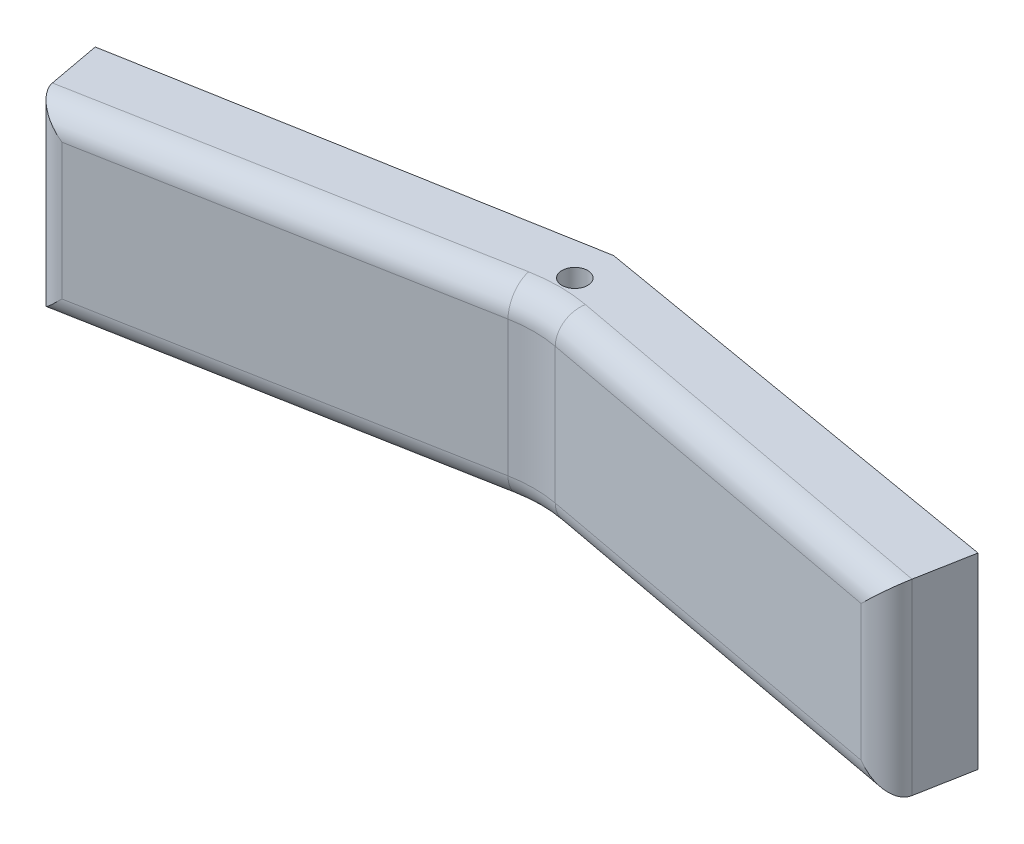
from build123d import *

# Parameters (mm, degrees)
ESQUISSE1_W              = 140
ESQUISSE1_H              = 30
BOSS_EXTRU_1_DEPTH       = 20
ESQUISSE3_W              = 140
ESQUISSE3_H              = 30
BOSS_EXTRU_2_DEPTH       = 20
BOSS_EXTRU_3_DEPTH       = 30
BOSS_EXTRU_4_DEPTH       = 30
ESQUISSE12_W             = 140
ESQUISSE12_H             = 30
ENL_V_MAT_EXTRU_1_DEPTH  = 41
ESQUISSE13_R             = 2
ENL_V_MAT_EXTRU_2_DEPTH  = 31
ESQUISSE25_R             = 2.5
ENL_V_MAT_EXTRU_11_DEPTH = 3
ENL_V_MAT_EXTRU_5_DEPTH  = 31
ENL_V_MAT_EXTRU_6_DEPTH  = 31
ESQUISSE19_W             = 12.781453569
ESQUISSE19_H             = 30
ENL_V_MAT_EXTRU_7_DEPTH  = 2
ESQUISSE20_W             = 12.289859201
ESQUISSE20_H             = 30
ENL_V_MAT_EXTRU_8_DEPTH  = 2
ENL_V_MAT_EXTRU_9_DEPTH  = 0.5
ENL_V_MAT_EXTRU_10_DEPTH = 0.5
ESQUISSE15_R             = 2.5
ENL_V_MAT_EXTRU_15_DEPTH = 3
CONG_1_R                 = 20
CONG_3_R                 = 4


with BuildPart() as part:
    # Esquisse1 → Boss.-Extru.1 (new body)
    with BuildSketch(Plane.XY):
        with Locations((70, 15)):
            Rectangle(ESQUISSE1_W, ESQUISSE1_H)
    extrude(amount=BOSS_EXTRU_1_DEPTH)

    # Esquisse3 → Boss.-Extru.2 (add)
    with BuildSketch(Plane.XY.offset(20)):
        with Locations((70, 15)):
            Rectangle(ESQUISSE3_W, ESQUISSE3_H)
    extrude(amount=BOSS_EXTRU_2_DEPTH)

    # Esquisse5 → Boss.-Extru.3 (add)
    with BuildSketch(Plane.XZ):
        Polygon((70, 12), (140, 25), (140, 12), (70, 0), align=None)
    extrude(amount=BOSS_EXTRU_3_DEPTH)

    # Esquisse6 → Boss.-Extru.4 (add)
    with BuildSketch(Plane.XZ):
        Polygon((0, 25), (0, 12.5), (70, 0), (70, 12), align=None)
    extrude(amount=BOSS_EXTRU_4_DEPTH)

    # Esquisse12 → Enlèv. mat.-Extru.1 (cut, through all)
    with BuildSketch(Plane.XY.offset(40)):
        with Locations((70, 15)):
            Rectangle(ESQUISSE12_W, ESQUISSE12_H)
    extrude(amount=-ENL_V_MAT_EXTRU_1_DEPTH, mode=Mode.SUBTRACT)

    # Esquisse13 → Enlèv. mat.-Extru.2 (cut, through all)
    with BuildSketch(Plane.XZ.offset(30)):
        with Locations((70, 6)):
            Circle(ESQUISSE13_R)
    extrude(amount=-ENL_V_MAT_EXTRU_2_DEPTH, mode=Mode.SUBTRACT)

    # Esquisse25 → Enlèv. mat.-Extru.11 (cut)
    with BuildSketch(Plane(origin=(2.1631644, 0, 12.113720643), x_dir=(-0.984427576, 0, 0.175790638), z_dir=(-0.175790638, 0, -0.984427576))):
        with Locations((-12.309930286, -15)):
            Circle(ESQUISSE25_R)
    extrude(amount=-ENL_V_MAT_EXTRU_11_DEPTH, mode=Mode.SUBTRACT)

    # Esquisse16 → Enlèv. mat.-Extru.5 (cut, through all)
    with BuildSketch(Plane(origin=(0, 0, 0), x_dir=(1, 0, 0), z_dir=(0, 1, 0))):
        Polygon((0, -12.5), (2.244032354, -24.583251134), (0, -25), align=None)
    extrude(amount=-ENL_V_MAT_EXTRU_5_DEPTH, mode=Mode.SUBTRACT)

    # Esquisse17 → Enlèv. mat.-Extru.6 (cut, through all)
    with BuildSketch(Plane(origin=(0, 0, 0), x_dir=(1, 0, 0), z_dir=(0, 1, 0))):
        Polygon((140, -12), (137.666206352, -24.56658118), (140, -25), align=None)
    extrude(amount=-ENL_V_MAT_EXTRU_6_DEPTH, mode=Mode.SUBTRACT)

    # Esquisse19 → Enlèv. mat.-Extru.7 (cut)
    with BuildSketch(Plane(origin=(137.486683764, 0, 25.53324127), x_dir=(0.182592194, 0, -0.983188736), z_dir=(0.983188736, 0, 0.182592194))):
        with Locations((7.373915521, -15)):
            Rectangle(ESQUISSE19_W, ESQUISSE19_H)
    extrude(amount=-ENL_V_MAT_EXTRU_7_DEPTH, mode=Mode.SUBTRACT)

    # Esquisse20 → Enlèv. mat.-Extru.8 (cut)
    with BuildSketch(Plane(origin=(-2.244032354, 0, 0.416748866), x_dir=(0.182592194, 0, 0.983188736), z_dir=(-0.983188736, 0, 0.182592194))):
        with Locations((18.434788802, -15)):
            Rectangle(ESQUISSE20_W, ESQUISSE20_H)
    extrude(amount=-ENL_V_MAT_EXTRU_8_DEPTH, mode=Mode.SUBTRACT)

    # Esquisse22 → Enlèv. mat.-Extru.9 (cut)
    with BuildSketch(Plane.XZ.offset(30)):
        Polygon((4.210409826, 24.218066747), (1.968902204, 12.148410321), (70, 0), (138.028566573, 11.662039984), (135.69982888, 24.201396792), (70, 12), align=None)
    extrude(amount=-ENL_V_MAT_EXTRU_9_DEPTH, mode=Mode.SUBTRACT)

    # Esquisse23 → Enlèv. mat.-Extru.10 (cut)
    with BuildSketch(Plane(origin=(0, 0, 0), x_dir=(1, 0, 0), z_dir=(0, 1, 0))):
        Polygon((1.968902204, -12.148410321), (4.210409826, -24.218066747), (70, -12), (135.69982888, -24.201396792), (138.028566573, -11.662039984), (70, 0), align=None)
    extrude(amount=-ENL_V_MAT_EXTRU_10_DEPTH, mode=Mode.SUBTRACT)

    # Esquisse15 → Enlèv. mat.-Extru.15 (cut)
    with BuildSketch(Plane(origin=(1.998413957, 0, -11.65741475), x_dir=(-0.985622255, 0, -0.168963815), z_dir=(0.168963815, 0, -0.985622255))):
        with Locations((-125.593557837, -15)):
            Circle(ESQUISSE15_R)
    extrude(amount=-ENL_V_MAT_EXTRU_15_DEPTH, mode=Mode.SUBTRACT)

    # Congé1
    cong_1_edges = [part.edges().sort_by_distance(p)[0] for p in [
        (70, -15, 12),
    ]]
    fillet(cong_1_edges, radius=CONG_1_R)

    # Congé3
    cong_3_edges = [part.edges().sort_by_distance(p)[0] for p in [
        (4.210409826, -15, 24.218066747),
        (104.675836379, -29.5, 18.439798185),
        (135.69982888, -15, 24.201396792),
        (35.279282974, -0.5, 18.448133162),
        (35.279282974, -29.5, 18.448133162),
        (104.675836379, -0.5, 18.439798185),
        (70, -0.5, 12.341974299),
        (70, -29.5, 12.341974299),
    ]]
    fillet(cong_3_edges, radius=CONG_3_R)


solid = part.part
